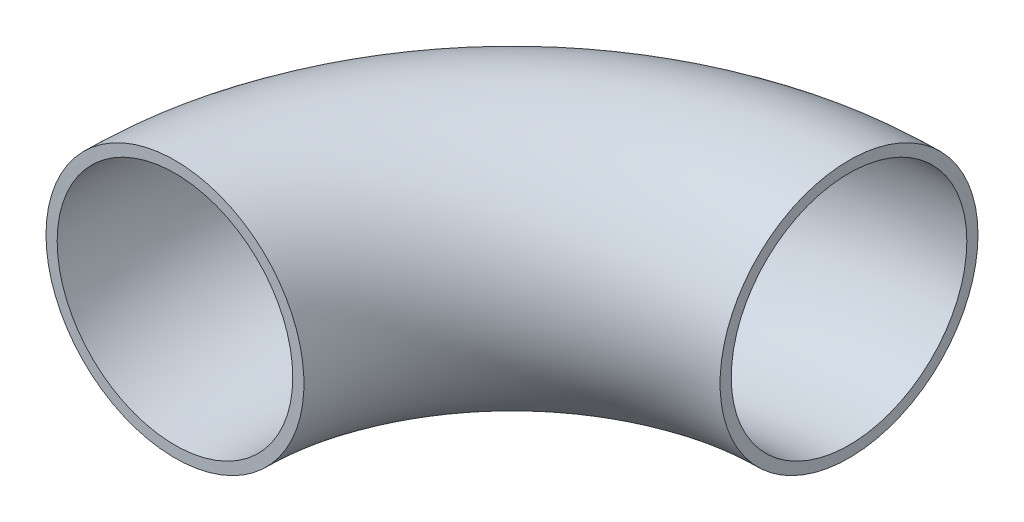
from build123d import *

# Parameters (mm, degrees)
SKETCH6_R   = 19.05
SKETCH6_R_2 = 17.399


with BuildPart() as part:
    # Sweep-Thin1: sweep along a path in Sketch2
    with BuildLine(Plane(origin=(0, 0, 0), x_dir=(1, 0, 0), z_dir=(0, 1, 0))) as sweep_thin1_path:
        ThreePointArc((0, 49.784), (-35.202603995, 35.202603995), (-49.784, 0))
    # Sketch6 → Sweep-Thin1 (sweep)
    with BuildSketch(Plane(origin=(0, 0, -49.784), x_dir=(0, 0, 1), z_dir=(-1, 0, 0))):
        Circle(SKETCH6_R)
        Circle(SKETCH6_R_2, mode=Mode.SUBTRACT)
    sweep(path=sweep_thin1_path.line)


solid = part.part
